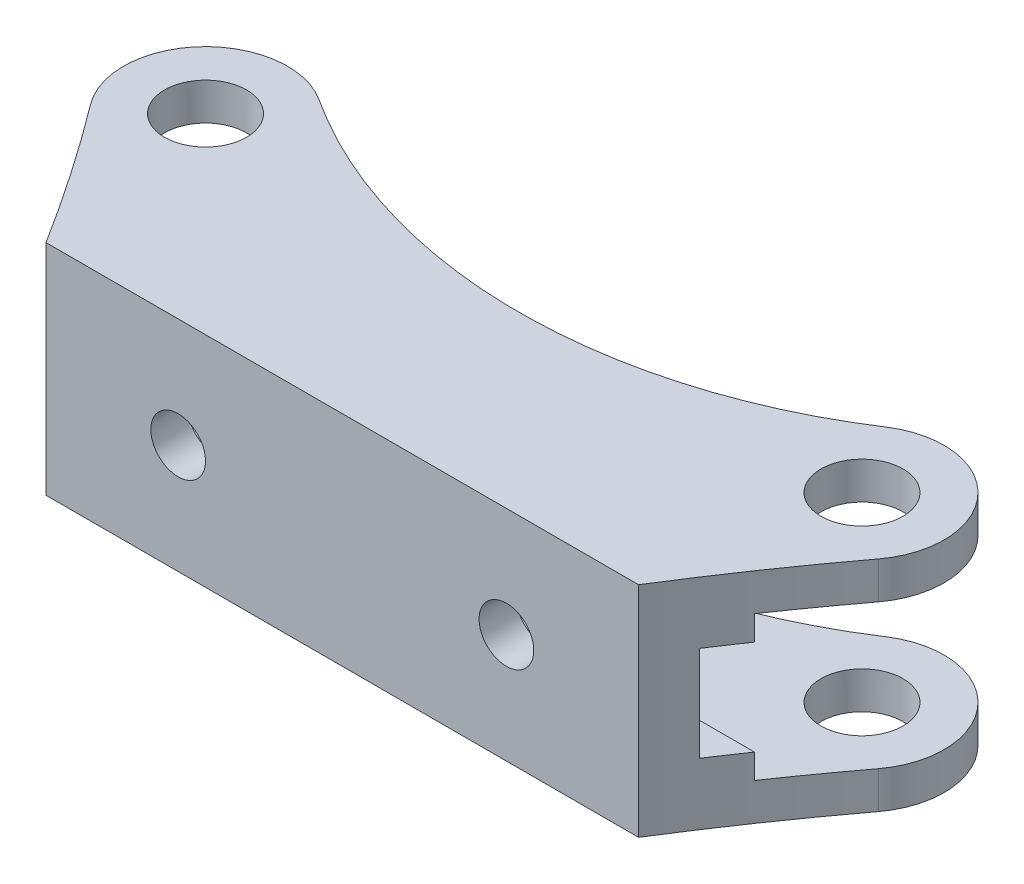
from build123d import *

# Parameters (mm, degrees)
EXTRUDE1_DEPTH            = 47.625
SKETCH4_R                 = 4.7625
SPHERICALHOLES_DEPTH      = 13.7
SPHERICALHOLES_DEPTH_BACK = 13.7
FILLET1_R                 = 9.525
SKETCH5_R                 = 3.175
EXTRUDE2_DEPTH            = 5.318
EXTRUDE3_START            = -47.625
SKETCH6_W                 = 3.81
SKETCH6_H                 = 2.8575
EXTRUDE3_DEPTH            = 95.25
CUT_EXTRUDE1_DEPTH        = 26.4
CUT_EXTRUDE3_DEPTH        = 26.4


with BuildPart() as part:
    # Sketch2 → Extrude1 (new body, symmetric)
    with BuildSketch(Plane(origin=(0, 0, 0), x_dir=(0, 0, -1), z_dir=(1, 0, 0))):
        Polygon((4.318, -8.382), (4.318, 8.382), (31.75, 8.382), (31.75, 12.7), (0, 12.7), (0, -12.7), (31.75, -12.7), (31.75, -8.382), align=None)
    extrude(amount=EXTRUDE1_DEPTH, both=True)

    # Sketch4 → SphericalHoles (cut, two sides)
    with BuildSketch(Plane(origin=(0, 0, 0), x_dir=(1, 0, 0), z_dir=(0, 1, 0))) as sphericalholes_sk:
        with Locations((38.1, 22.225)):
            Circle(SKETCH4_R)
        with Locations((-38.1, 22.225)):
            Circle(SKETCH4_R)
    extrude(amount=SPHERICALHOLES_DEPTH, mode=Mode.SUBTRACT)
    extrude(sphericalholes_sk.sketch, amount=-SPHERICALHOLES_DEPTH_BACK, mode=Mode.SUBTRACT)

    # Fillet1
    fillet1_edges = [part.edges().sort_by_distance(p)[0] for p in [
        (-47.625, 10.541, -31.75),
        (47.625, -10.541, -31.75),
        (47.625, 10.541, -31.75),
        (-47.625, -10.541, -31.75),
    ]]
    fillet(fillet1_edges, radius=FILLET1_R)

    # Sketch5 → Extrude2 (cut, through all)
    with BuildSketch(Plane(origin=(0, 0, -4.318), x_dir=(-1, 0, 0), z_dir=(0, 0, -1))):
        with Locations((19.05, 0)):
            Circle(SKETCH5_R)
        with Locations((-19.05, 0)):
            Circle(SKETCH5_R)
    extrude(amount=-EXTRUDE2_DEPTH, mode=Mode.SUBTRACT)

    # Sketch6 → Extrude3 (add)
    with BuildSketch(Plane(origin=(0, 0, 0), x_dir=(0, 0, -1), z_dir=(1, 0, 0)).offset(EXTRUDE3_START)):
        with Locations((6.223, -6.95325)):
            Rectangle(SKETCH6_W, SKETCH6_H)
        with Locations((6.223, 6.95325)):
            Rectangle(SKETCH6_W, SKETCH6_H)
    extrude(amount=EXTRUDE3_DEPTH)

    # Sketch12 → Cut-Extrude1 (cut, through all)
    with BuildSketch(Plane(origin=(0, 12.7, 0), x_dir=(1, 0, 0), z_dir=(0, 1, 0))):
        with BuildLine():
            Line((-34.3916, 0), (-47.625, 0))
            Line((-47.625, 0), (-47.625, 22.225))
            ThreePointArc((-47.625, 22.225), (-47.136208414, 19.212930529), (-45.72, 16.51))
            ThreePointArc((-45.72, 16.51), (-39.881889157, 8.374329594), (-34.3916, 0))
        make_face()
        with BuildLine():
            Line((47.625, 22.225), (47.625, 0))
            Line((47.625, 0), (34.3916, 0))
            ThreePointArc((34.3916, 0), (39.881889157, 8.374329594), (45.72, 16.51))
            ThreePointArc((45.72, 16.51), (47.136208414, 19.212930529), (47.625, 22.225))
        make_face()
    extrude(amount=-CUT_EXTRUDE1_DEPTH, mode=Mode.SUBTRACT)

    # Sketch13 → Cut-Extrude3 (cut, through all)
    with BuildSketch(Plane(origin=(0, 12.7, 0), x_dir=(1, 0, 0), z_dir=(0, 1, 0))):
        with BuildLine():
            Line((38.1, 31.75), (-38.1, 31.75))
            ThreePointArc((-38.1, 31.75), (-35.390312481, 31.356441209), (-32.904545455, 30.20828736))
            ThreePointArc((-32.904545455, 30.20828736), (0, 20.444107304), (32.904545455, 30.20828736))
            ThreePointArc((32.904545455, 30.20828736), (35.390312481, 31.356441209), (38.1, 31.75))
        make_face()
    extrude(amount=-CUT_EXTRUDE3_DEPTH, mode=Mode.SUBTRACT)


solid = part.part
